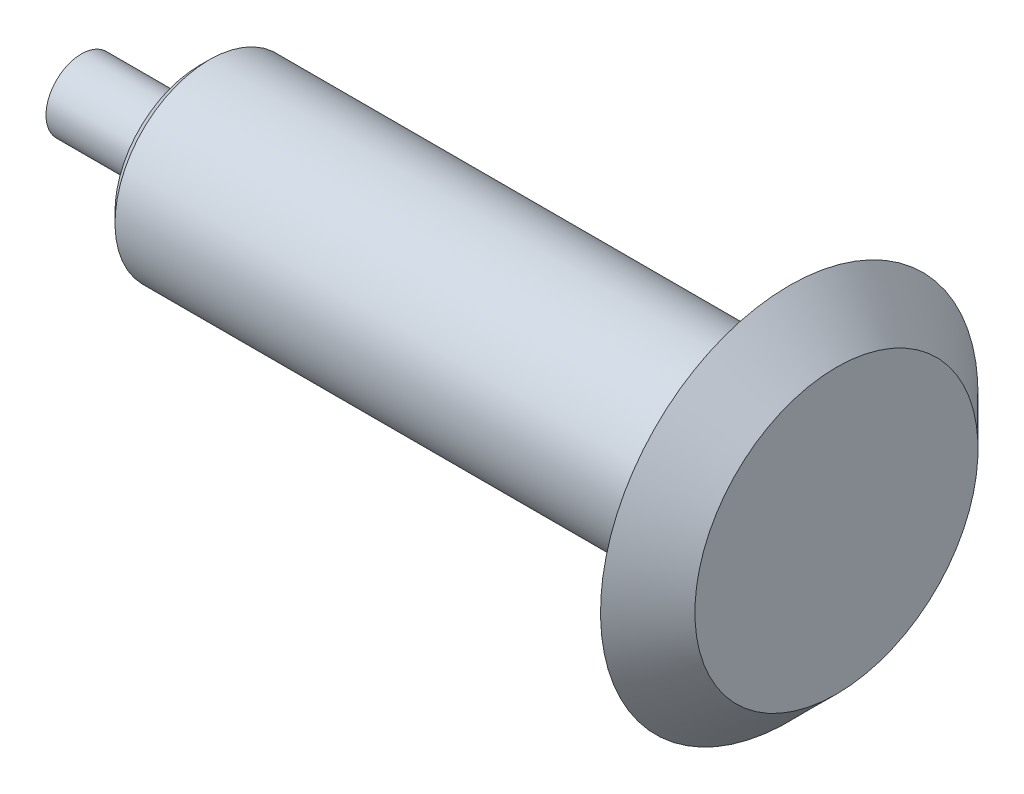
from build123d import *


with BuildPart() as part:
    # Croquis1 → Revolución1 (revolve)
    with BuildSketch(Plane.XY):
        Polygon((0, 0), (0, 7.5), (25, 7.5), (25, 17.878679656), (27.121320344, 20), (140, 20), (150, 30), (150, 40), (160, 30), (160, 0), align=None)
    revolve(axis=Axis((160, 0, 0), (-1, 0, 0)))


solid = part.part
